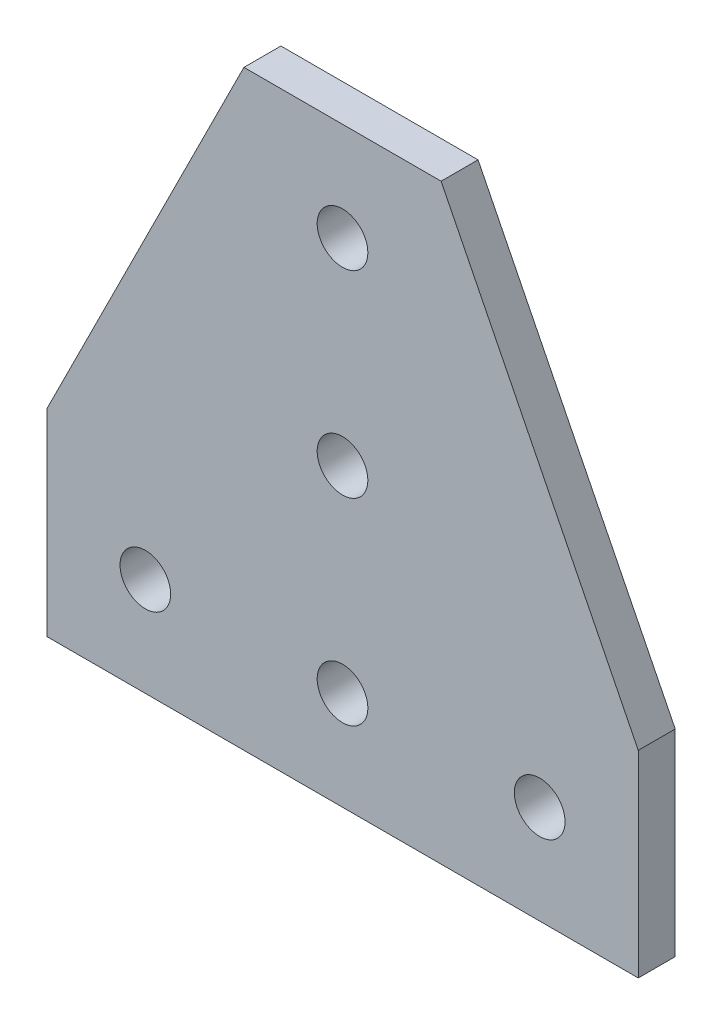
from build123d import *

# Parameters (mm, degrees)
SKETCH1_R           = 3.2639
BOSS_EXTRUDE1_DEPTH = 2.38125


with BuildPart() as part:
    # Sketch1 → Boss-Extrude1 (new body, symmetric)
    with BuildSketch(Plane.XY):
        Polygon((0, 0), (0, 25.4), (25.4, 76.2), (50.8, 76.2), (76.2, 25.4), (76.2, 0), align=None)
        with Locations((12.7, 12.7)):
            Circle(SKETCH1_R, mode=Mode.SUBTRACT)
        with Locations((38.1, 12.7)):
            Circle(SKETCH1_R, mode=Mode.SUBTRACT)
        with Locations((63.5, 12.7)):
            Circle(SKETCH1_R, mode=Mode.SUBTRACT)
        with Locations((38.1, 38.1)):
            Circle(SKETCH1_R, mode=Mode.SUBTRACT)
        with Locations((38.1, 63.5)):
            Circle(SKETCH1_R, mode=Mode.SUBTRACT)
    extrude(amount=BOSS_EXTRUDE1_DEPTH, both=True)


solid = part.part
